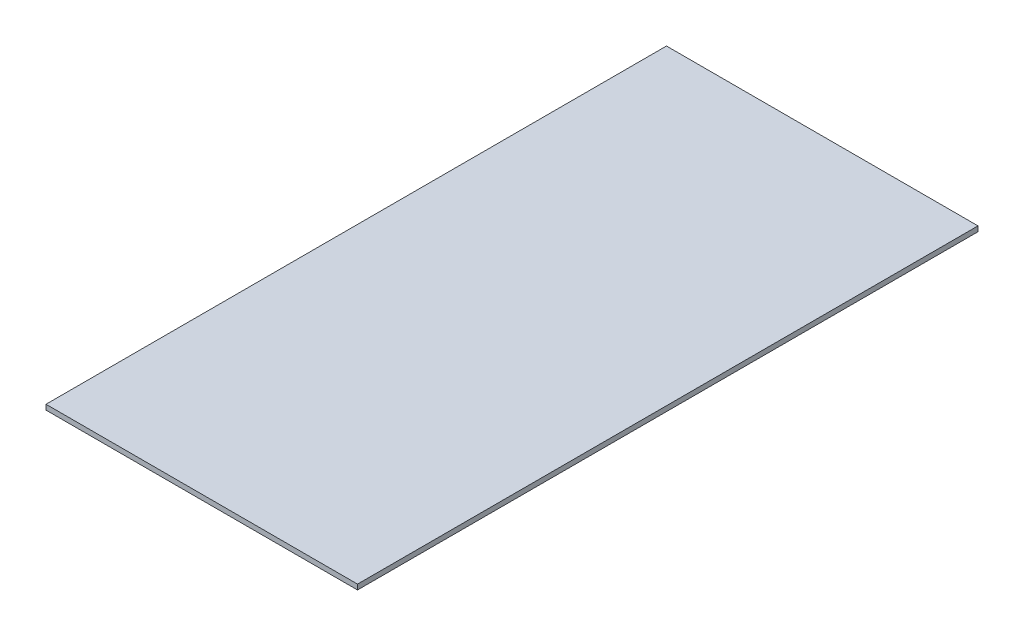
from build123d import *

# Parameters (mm, degrees)
SKETCH_1_W      = 1220
SKETCH_1_H      = 2430
EXTRUDE_1_DEPTH = 20


with BuildPart() as part:
    # 草图1 → 凸台-拉伸1 (new body)
    with BuildSketch(Plane(origin=(0, 0, 0), x_dir=(1, 0, 0), z_dir=(0, 1, 0))):
        with Locations((610, -1215)):
            Rectangle(SKETCH_1_W, SKETCH_1_H)
    extrude(amount=-EXTRUDE_1_DEPTH)


solid = part.part
